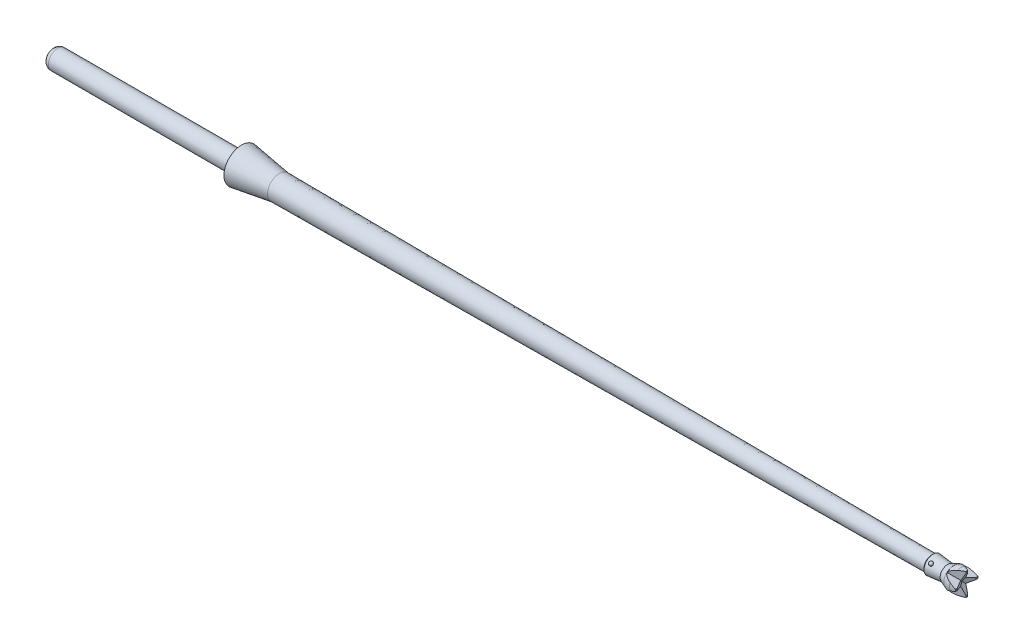
from build123d import *

# Parameters (mm, degrees)
FILLET1_R               = 2
CUT_EXTRUDE1_DEPTH      = 2.85
CUT_EXTRUDE2_DEPTH      = 2.85
CUT_EXTRUDE2_DEPTH_BACK = 2.85
BODY_MOVE_COPY1_ANGLE   = 90
FILLET2_R               = 0.6
BODY_MOVE_COPY2_ANGLE   = 45
BODY_MOVE_COPY3_ANGLE   = 180


with BuildPart() as part:
    # Sketch1 → Revolve1 (revolve)
    with BuildSketch(Plane.XY):
        Polygon((0, 1), (0, 1.85), (4, 1.25), (72.9, 0.8), (73.05, 0.95), (74.6, 0.8), (75.6, 1.2), (76.6, 1.2), (76.6, 0), (0, 0), (-20, 0), (-20, 1), align=None)
    revolve(axis=Axis((76.6, 0, 0), (-1, 0, 0)))

    # Fillet1
    fillet1_edges = [part.edges().sort_by_distance(p)[0] for p in [
        (75.6, -1.2, 0),
    ]]
    fillet(fillet1_edges, radius=FILLET1_R)

    # Sketch2 → Cut-Extrude1 (cut, symmetric)
    with BuildSketch(Plane.XY):
        Polygon((76.6, 0.1), (75.3, 0.697004061), (75.3, 1.3), (76.6, 1.3), align=None)
    cut_extrude1 = extrude(amount=CUT_EXTRUDE1_DEPTH, both=True, mode=Mode.SUBTRACT)

    # Mirror1: Cut-Extrude1 across plane
    add(cut_extrude1.mirror(Plane.ZX), mode=Mode.SUBTRACT)

    # Sketch3 → Cut-Extrude2 (cut, two sides)
    with BuildSketch(Plane(origin=(0, 0, 0), x_dir=(1, 0, 0), z_dir=(0, 1, 0))) as cut_extrude2_sk:
        Polygon((76.6, 1), (76.6, -1), (76.1, 0), align=None)
    extrude(amount=CUT_EXTRUDE2_DEPTH, mode=Mode.SUBTRACT)
    extrude(cut_extrude2_sk.sketch, amount=-CUT_EXTRUDE2_DEPTH_BACK, mode=Mode.SUBTRACT)


with BuildPart() as body_2:
    # Split1: the piece on the far side of the plane
    add(part.part)
    split(bisect_by=Plane(origin=(74.6, 0, 0), x_dir=(0, 0, 1), z_dir=(1, 0, 0)), keep=Keep.BOTTOM)


with BuildPart() as part_1:
    add(part.part)

    # Split1
    split(bisect_by=Plane(origin=(74.6, 0, 0), x_dir=(0, 0, 1), z_dir=(1, 0, 0)), keep=Keep.TOP)


with BuildPart() as body_3:
    # Body-Move/Copy1: copy of part
    add(part_1.part.rotate(Axis((0, 0, -0.015428444), (1, 0, 0)), BODY_MOVE_COPY1_ANGLE))


with BuildPart() as body_2_1:
    add(body_2.part)

    # Combine1: union body 3, part
    add(body_3.part)
    add(part_1.part)

    # Fillet2
    fillet2_edges = [body_2_1.edges().sort_by_distance(p)[0] for p in [
        (-20, -1, 0),
    ]]
    fillet(fillet2_edges, radius=FILLET2_R)


with BuildPart() as body_2_2:
    # Sketch5 → Revolve2 (revolve)
    with BuildSketch(Plane.XY):
        with BuildLine():
            Line((73.5, 1.106451613), (73.5, 0.706451613))
            ThreePointArc((73.5, 0.706451613), (73.7, 0.906451613), (73.5, 1.106451613))
        make_face()
    revolve(axis=Axis((73.5, 1.106451613, 0), (0, -1, 0)))


with BuildPart() as body_2_2_1:
    # Body-Move/Copy2: moved
    add(body_2_2.part.rotate(Axis((0, -0.015428444, 0), (1, 0, 0)), BODY_MOVE_COPY2_ANGLE))


with BuildPart() as body_3_2:
    # Body-Move/Copy3: copy of body 2 2
    add(body_2_2_1.part.rotate(Axis((0, -0.015428444, 0), (1, 0, 0)), BODY_MOVE_COPY3_ANGLE))


solid = Compound([body_2_1.part, body_2_2_1.part, body_3_2.part])
